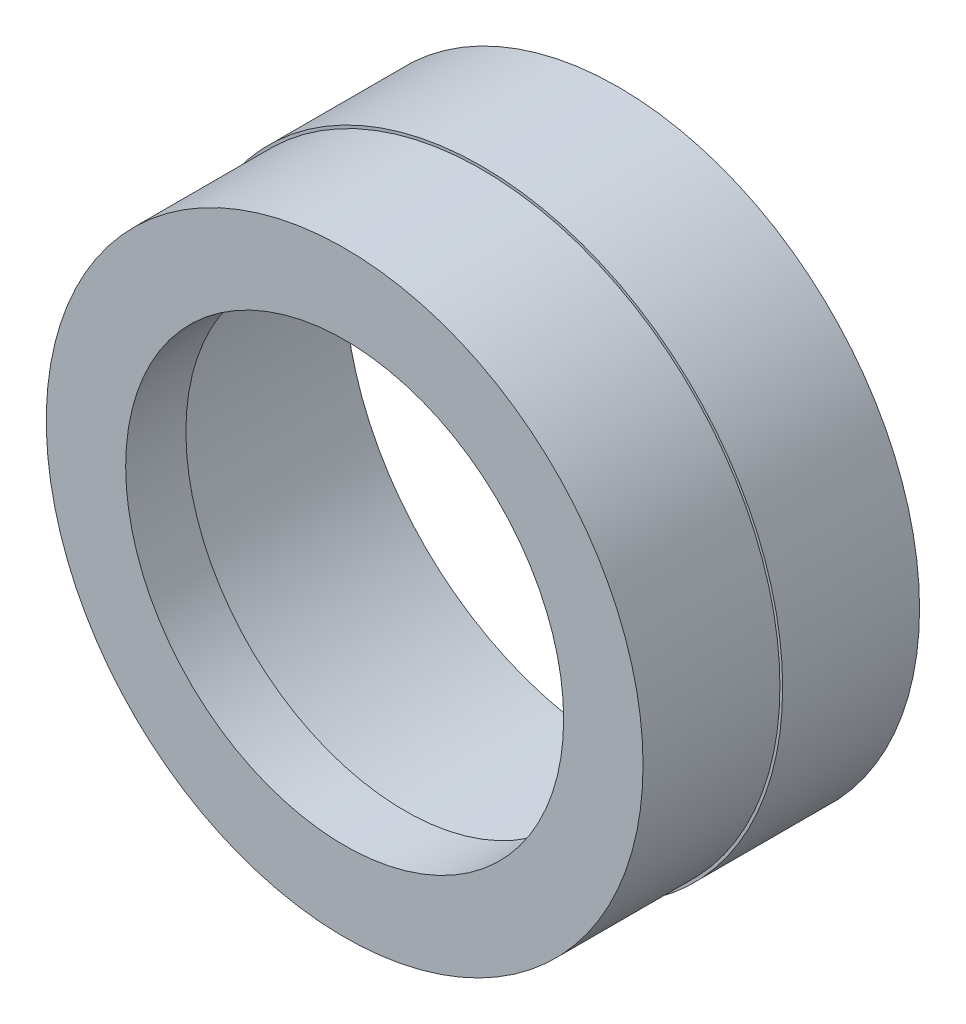
from build123d import *

# Parameters (mm, degrees)
SKETCH1_R           = 5.5
BOSS_EXTRUDE1_DEPTH = 5
SKETCH2_R           = 5
CUT_EXTRUDE1_DEPTH  = 3.9
CUT_EXTRUDE2_REACH  = 7
SKETCH3_R           = 4
SKETCH4_OUTSIDE_W   = 16.268
SKETCH4_OUTSIDE_H   = 16.268
SKETCH4_OUTSIDE_R   = 5.45
CUT_EXTRUDE3_DEPTH  = 2.5


with BuildPart() as part:
    # Sketch1 → Boss-Extrude1 (new body)
    with BuildSketch(Plane.XY):
        Circle(SKETCH1_R)
    extrude(amount=-BOSS_EXTRUDE1_DEPTH)

    # Sketch2 → Cut-Extrude1 (cut)
    with BuildSketch(Plane(origin=(0, 0, -5), x_dir=(-1, 0, 0), z_dir=(0, 0, -1))):
        Circle(SKETCH2_R)
    extrude(amount=-CUT_EXTRUDE1_DEPTH, mode=Mode.SUBTRACT)

    # Sketch3 → Cut-Extrude2 (cut, up to next)
    with BuildSketch(Plane.XY, mode=Mode.PRIVATE) as cut_extrude2_sk1:
        Circle(SKETCH3_R)
    cut_extrude2_tool1 = extrude(cut_extrude2_sk1.sketch, amount=-CUT_EXTRUDE2_REACH, mode=Mode.PRIVATE) & part.part
    add(cut_extrude2_tool1.solids().sort_by_distance((0, 0, 0))[0], mode=Mode.SUBTRACT)

    # Sketch4 outside → Cut-Extrude3 (cut)
    with BuildSketch(Plane.XY):
        Rectangle(SKETCH4_OUTSIDE_W, SKETCH4_OUTSIDE_H)
        Circle(SKETCH4_OUTSIDE_R, mode=Mode.SUBTRACT)
    extrude(amount=-CUT_EXTRUDE3_DEPTH, mode=Mode.SUBTRACT)


solid = part.part
